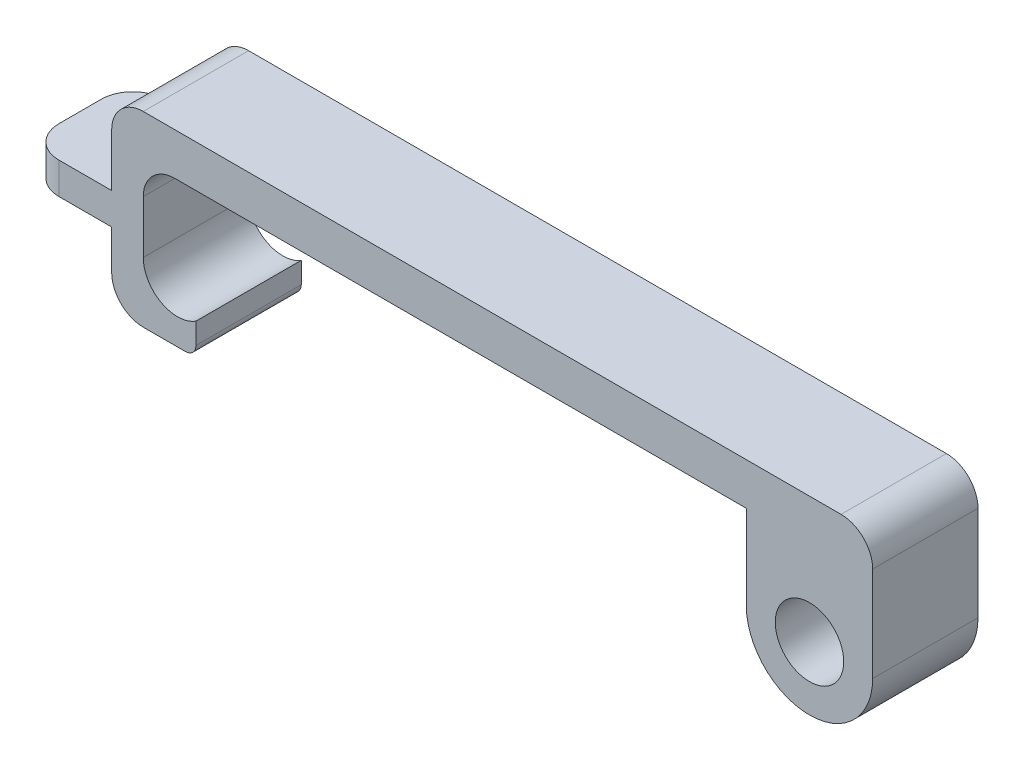
from build123d import *

# Parameters (mm, degrees)
ESQUISSE1_R        = 3.25
BOSS_EXTRU_1_DEPTH = 10
CONG_1_R           = 3
CONG_2_R           = 1


with BuildPart() as part:
    # Esquisse1 → Boss.-Extru.1 (new body)
    with BuildSketch(Plane.XY):
        with BuildLine():
            Line((11.588403104, 18.910210832), (11.588403104, 26.910210832))
            Line((11.588403104, 26.910210832), (-45.661596896, 26.910210832))
            Line((-45.661596896, 26.910210832), (-45.661596896, 18.910210832))
            ThreePointArc((-45.661596896, 18.910210832), (-43.972846395, 16.059772269), (-40.661596896, 16.171598045))
            Line((-40.661596896, 16.171598045), (-40.661596896, 13.171598045))
            Line((-40.661596896, 13.171598045), (-48.661596896, 13.171598045))
            Line((-48.661596896, 13.171598045), (-48.661596896, 19.910210832))
            Line((-48.661596896, 19.910210832), (-56.661596896, 19.910210832))
            Line((-56.661596896, 19.910210832), (-56.661596896, 22.910210832))
            Line((-56.661596896, 22.910210832), (-48.661596896, 22.910210832))
            Line((-48.661596896, 22.910210832), (-48.661596896, 30.910210832))
            Line((-48.661596896, 30.910210832), (23.588403104, 30.910210832))
            Line((23.588403104, 30.910210832), (23.588403104, 18.910210832))
            ThreePointArc((23.588403104, 18.910210832), (17.588403104, 12.910210832), (11.588403104, 18.910210832))
        make_face()
        with Locations((17.588403104, 18.910210832)):
            Circle(ESQUISSE1_R, mode=Mode.SUBTRACT)
    extrude(amount=BOSS_EXTRU_1_DEPTH)

    # Congé1
    cong_1_edges = [part.edges().sort_by_distance(p)[0] for p in [
        (-56.661596896, 21.410210832, 0),
        (-48.661596896, 30.910210832, 5),
        (23.588403104, 30.910210832, 5),
        (-45.661596896, 26.910210832, 5),
        (-48.661596896, 13.171598045, 5),
        (-56.661596896, 21.410210832, 10),
    ]]
    fillet(cong_1_edges, radius=CONG_1_R)

    # Congé2
    cong_2_edges = [part.edges().sort_by_distance(p)[0] for p in [
        (-40.661596896, 13.171598045, 5),
    ]]
    fillet(cong_2_edges, radius=CONG_2_R)


solid = part.part
